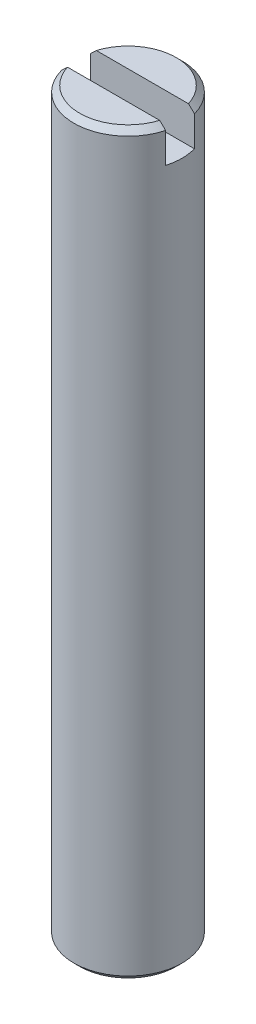
from build123d import *

# Parameters (mm, degrees)
SKETCH1_R           = 4.7625
BOSS_EXTRUDE1_DEPTH = 65.1002
CHAMFER1_SIZE       = 0.508
CUT_EXTRUDE1_DEPTH  = 3.175


with BuildPart() as part:
    # Sketch1 → Boss-Extrude1 (new body)
    with BuildSketch(Plane(origin=(0, 0, 0), x_dir=(1, 0, 0), z_dir=(0, 1, 0))):
        Circle(SKETCH1_R)
    extrude(amount=BOSS_EXTRUDE1_DEPTH)

    # Chamfer1
    chamfer1_edges = [part.edges().sort_by_distance(p)[0] for p in [
        (-4.7625, 0, 0),
        (-4.7625, 65.1002, 0),
    ]]
    chamfer(chamfer1_edges, length=CHAMFER1_SIZE)

    # Sketch2 → Cut-Extrude1 (cut)
    with BuildSketch(Plane(origin=(0, 65.1002, 0), x_dir=(1, 0, 0), z_dir=(0, 1, 0))):
        with BuildLine():
            Line((-4.590186764, -1.270018988), (4.65003157, -1.270018988))
            ThreePointArc((4.65003157, -1.270018988), (4.777248162, 0.003693467), (4.590049507, 1.269981012))
            Line((4.590049507, 1.269981012), (-4.649892524, 1.269981012))
            ThreePointArc((-4.649892524, 1.269981012), (-4.775788181, -0.003680045), (-4.590186764, -1.270018988))
        make_face()
    extrude(amount=-CUT_EXTRUDE1_DEPTH, mode=Mode.SUBTRACT)


solid = part.part
